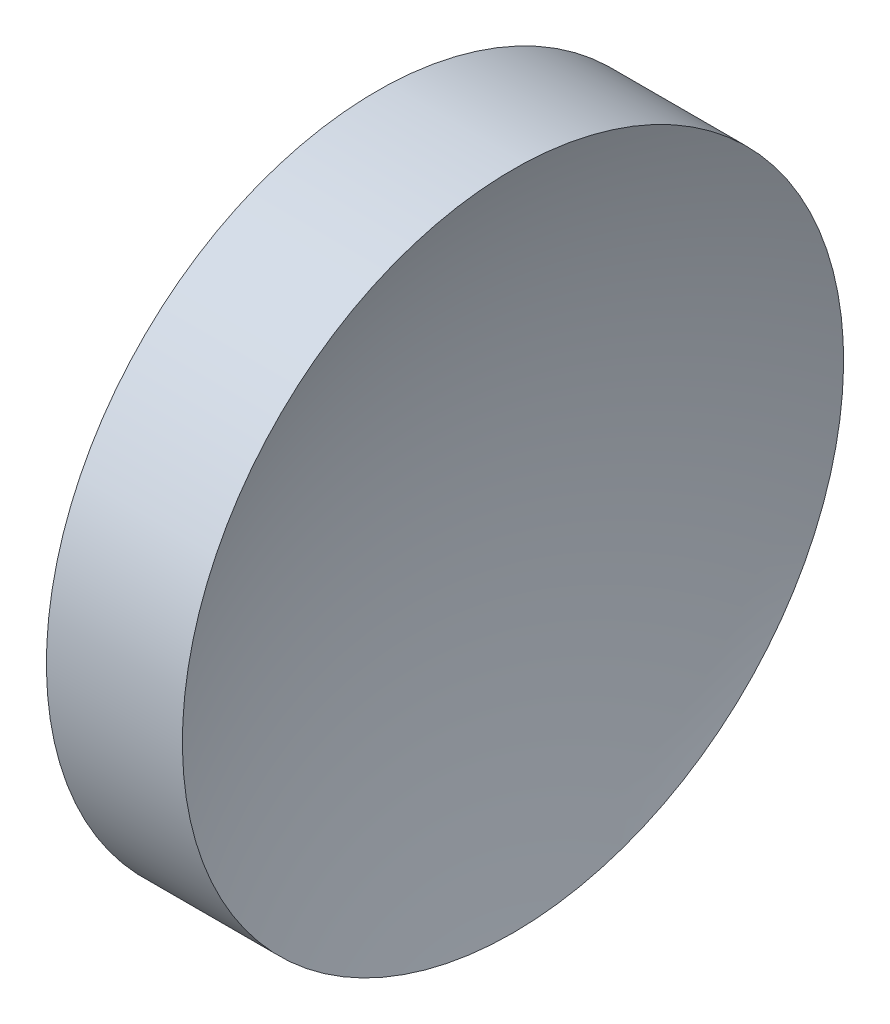
from build123d import *


with BuildPart() as part:
    # 草图1 → 旋转1 (revolve)
    with BuildSketch(Plane.XY, mode=Mode.PRIVATE) as revolve_1_sk:
        with BuildLine():
            Line((46.585470099, 26.023299941), (46.585470099, 36.023299941))
            Line((46.585470099, 36.023299941), (50.698896699, 36.023299941))
            ThreePointArc((50.698896699, 36.023299941), (49.193827272, 31.123640289), (48.685470099, 26.023299941))
            Line((48.685470099, 26.023299941), (46.585470099, 26.023299941))
        make_face()
    revolve(revolve_1_sk.sketch.rotate(Axis((44.704833672, 26.023299941, 0), (1, 0, 0)), 180), axis=Axis((44.704833672, 26.023299941, 0), (1, 0, 0)))  # turned: the seam where the file's is


solid = part.part
